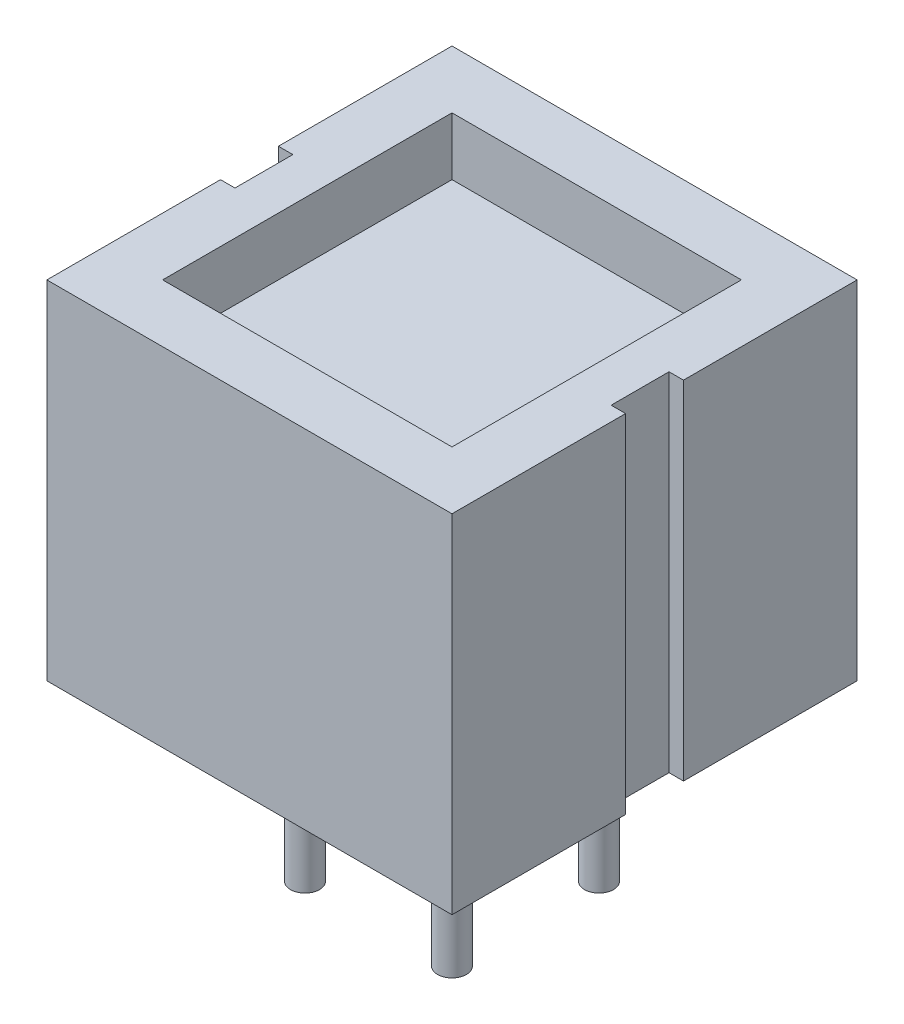
from build123d import *

# Parameters (mm, degrees)
CROQUIS1_W              = 7
CROQUIS1_H              = 7
SALIENTE_EXTRUIR1_DEPTH = 6
CROQUIS2_R              = 0.25
SALIENTE_EXTRUIR2_DEPTH = 3
CROQUIS3_W              = 5
CROQUIS3_H              = 5
CORTAR_EXTRUIR1_DEPTH   = 1
CROQUIS4_W              = 0.5
CROQUIS4_H              = 1
CORTAR_EXTRUIR2_DEPTH   = 10


with BuildPart() as part:
    # Croquis1 → Saliente-Extruir1 (new body)
    with BuildSketch(Plane(origin=(0, 0, 0), x_dir=(1, 0, 0), z_dir=(0, 1, 0))):
        Rectangle(CROQUIS1_W, CROQUIS1_H)
    extrude(amount=SALIENTE_EXTRUIR1_DEPTH)

    # Croquis2 → Saliente-Extruir2 (add)
    with BuildSketch(Plane.XZ):
        with Locations((-1.27, 1.27)):
            Circle(CROQUIS2_R)
        with Locations((1.27, 1.27)):
            Circle(CROQUIS2_R)
        with Locations((1.27, -1.27)):
            Circle(CROQUIS2_R)
        with Locations((-1.27, -1.27)):
            Circle(CROQUIS2_R)
    extrude(amount=SALIENTE_EXTRUIR2_DEPTH)

    # Croquis3 → Cortar-Extruir1 (cut)
    with BuildSketch(Plane(origin=(0, 6, 0), x_dir=(1, 0, 0), z_dir=(0, 1, 0))):
        Rectangle(CROQUIS3_W, CROQUIS3_H)
    extrude(amount=-CORTAR_EXTRUIR1_DEPTH, mode=Mode.SUBTRACT)

    # Croquis4 → Cortar-Extruir2 (cut, through all)
    with BuildSketch(Plane(origin=(0, 6, 0), x_dir=(1, 0, 0), z_dir=(0, 1, 0))):
        with Locations((3.5, 0)):
            Rectangle(CROQUIS4_W, CROQUIS4_H)
        with Locations((-3.5, 0)):
            Rectangle(CROQUIS4_W, CROQUIS4_H)
    extrude(amount=-CORTAR_EXTRUIR2_DEPTH, mode=Mode.SUBTRACT)


solid = part.part
